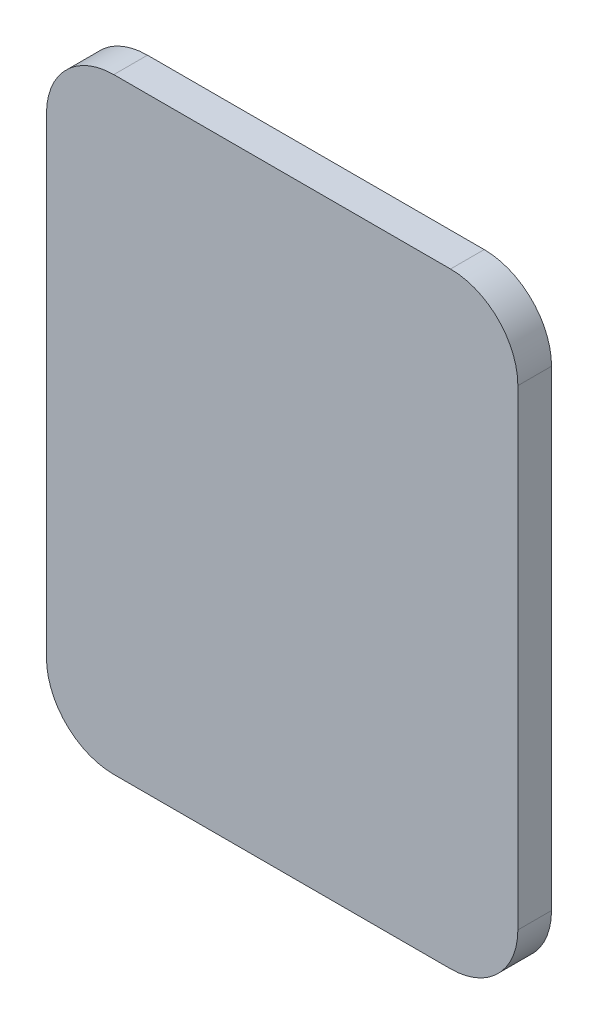
from build123d import *

# Parameters (mm, degrees)
SKETCH1_W           = 70
SKETCH1_H           = 90
BOSS_EXTRUDE1_DEPTH = 5
SKETCH3_W           = 5
SKETCH3_H           = 50
BOSS_EXTRUDE2_DEPTH = 20
SKETCH4_R           = 3
CUT_EXTRUDE1_DEPTH  = 48.5
FILLET1_R           = 3
FILLET2_R           = 10
FILLET3_R           = 10


with BuildPart() as part:
    # Sketch1 → Boss-Extrude1 (new body)
    with BuildSketch(Plane.XY):
        Rectangle(SKETCH1_W, SKETCH1_H)
    extrude(amount=BOSS_EXTRUDE1_DEPTH)

    # Sketch3 → Boss-Extrude2 (add)
    with BuildSketch(Plane(origin=(0, 0, 0), x_dir=(-1, 0, 0), z_dir=(0, 0, -1))):
        with Locations((10, 0)):
            Rectangle(SKETCH3_W, SKETCH3_H)
        with Locations((-10, 0)):
            Rectangle(SKETCH3_W, SKETCH3_H)
    extrude(amount=BOSS_EXTRUDE2_DEPTH)

    # Sketch4 → Cut-Extrude1 (cut, through all)
    with BuildSketch(Plane(origin=(12.5, 0, 0), x_dir=(0, 0, -1), z_dir=(1, 0, 0))):
        with Locations((10, 12.5)):
            Circle(SKETCH4_R)
        with Locations((10, -12.5)):
            Circle(SKETCH4_R)
    extrude(amount=-CUT_EXTRUDE1_DEPTH, mode=Mode.SUBTRACT)

    # Fillet1
    fillet1_edges = [part.edges().sort_by_distance(p)[0] for p in [
        (10, 25, 0),
        (12.5, 0, 0),
        (10, -25, 0),
        (-12.5, 0, 0),
        (-10, 25, 0),
        (-10, -25, 0),
    ]]
    fillet(fillet1_edges, radius=FILLET1_R)

    # Fillet2
    fillet2_edges = [part.edges().sort_by_distance(p)[0] for p in [
        (10, 25, -20),
        (10, -25, -20),
        (-10, 25, -20),
        (-10, -25, -20),
    ]]
    fillet(fillet2_edges, radius=FILLET2_R)

    # Fillet3
    fillet3_edges = [part.edges().sort_by_distance(p)[0] for p in [
        (35, -45, 2.5),
        (-35, -45, 2.5),
        (-35, 45, 2.5),
        (35, 45, 2.5),
    ]]
    fillet(fillet3_edges, radius=FILLET3_R)


solid = part.part
